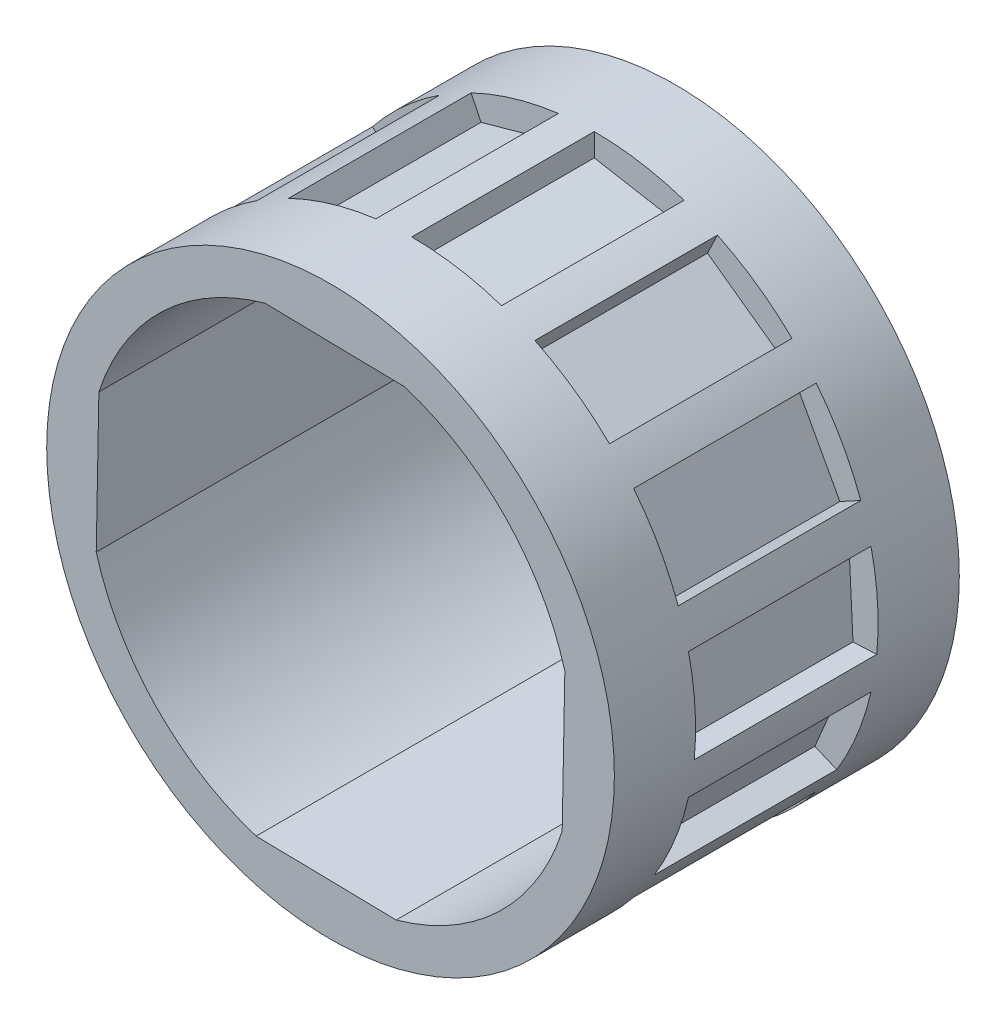
from build123d import *

# Parameters (mm, degrees)
BOSS_EXTRUDE1_DEPTH = 6.35
SKETCH3_R           = 9.875
BOSS_EXTRUDE3_DEPTH = 2.825
SKETCH7_R           = 9.875
BOSS_EXTRUDE5_DEPTH = 2.825


with BuildPart() as part:
    # Sketch1 → Boss-Extrude1 (new body)
    with BuildSketch(Plane.XY):
        with BuildLine():
            Line((0, 9.081), (2.981324224, 8.551667078))
            Line((2.981324224, 8.551667078), (3.126108811, 9.367127025))
            ThreePointArc((3.126108811, 9.367127025), (3.712801822, 9.150449586), (4.284601924, 8.897067571))
            Line((4.284601924, 8.897067571), (3.940098235, 8.181698289))
            Line((3.940098235, 8.181698289), (6.396509598, 6.411237704))
            Line((6.396509598, 6.411237704), (6.880770815, 7.083122051))
            ThreePointArc((6.880770815, 7.083122051), (7.315350136, 6.633345867), (7.720585889, 6.156961793))
            Line((7.720585889, 6.156961793), (7.099811692, 5.661910891))
            Line((7.099811692, 5.661910891), (8.544787799, 3.000984074))
            Line((8.544787799, 3.000984074), (9.272611772, 3.396217886))
            ThreePointArc((9.272611772, 3.396217886), (9.469003638, 2.802426646), (9.627413133, 2.197394223))
            Line((9.627413133, 2.197394223), (8.853320371, 2.020712601))
            Line((8.853320371, 2.020712601), (9.00066598, -1.003651256))
            Line((9.00066598, -1.003651256), (9.827898246, -0.963348883))
            ThreePointArc((9.827898246, -0.963348883), (9.74720484, -1.583547541), (9.627413133, -2.197394223))
            Line((9.627413133, -2.197394223), (8.853320371, -2.020712601))
            Line((8.853320371, -2.020712601), (7.673851879, -4.809501146))
            Line((7.673851879, -4.809501146), (8.436648941, -5.132112591))
            ThreePointArc((8.436648941, -5.132112591), (8.094852581, -5.655880717), (7.720585889, -6.156961793))
            Line((7.720585889, -6.156961793), (7.099811692, -5.661910891))
            Line((7.099811692, -5.661910891), (4.827137299, -7.66277035))
            Line((4.827137299, -7.66277035), (5.374417845, -8.284398459))
            ThreePointArc((5.374417845, -8.284398459), (4.839215493, -8.607997352), (4.284601924, -8.897067571))
            Line((4.284601924, -8.897067571), (3.940098235, -8.181698289))
            Line((3.940098235, -8.181698289), (1.024348976, -8.998333907))
            Line((1.024348976, -8.998333907), (1.247717382, -9.795857611))
            ThreePointArc((1.247717382, -9.795857611), (0.625112426, -9.855194542), (0, -9.875))
            Line((0, -9.875), (0, -9.081))
            Line((0, -9.081), (-2.981324224, -8.551667078))
            Line((-2.981324224, -8.551667078), (-3.126108811, -9.367127025))
            ThreePointArc((-3.126108811, -9.367127025), (-3.712801822, -9.150449586), (-4.284601924, -8.897067571))
            Line((-4.284601924, -8.897067571), (-3.940098235, -8.181698289))
            Line((-3.940098235, -8.181698289), (-6.396509598, -6.411237704))
            Line((-6.396509598, -6.411237704), (-6.880770815, -7.083122051))
            ThreePointArc((-6.880770815, -7.083122051), (-7.315350136, -6.633345867), (-7.720585889, -6.156961793))
            Line((-7.720585889, -6.156961793), (-7.099811692, -5.661910891))
            Line((-7.099811692, -5.661910891), (-8.544787799, -3.000984074))
            Line((-8.544787799, -3.000984074), (-9.272611772, -3.396217886))
            ThreePointArc((-9.272611772, -3.396217886), (-9.469003638, -2.802426646), (-9.627413133, -2.197394223))
            Line((-9.627413133, -2.197394223), (-8.853320371, -2.020712601))
            Line((-8.853320371, -2.020712601), (-9.00066598, 1.003651256))
            Line((-9.00066598, 1.003651256), (-9.827898246, 0.963348883))
            ThreePointArc((-9.827898246, 0.963348883), (-9.74720484, 1.583547541), (-9.627413133, 2.197394223))
            Line((-9.627413133, 2.197394223), (-8.853320371, 2.020712601))
            Line((-8.853320371, 2.020712601), (-7.673851879, 4.809501146))
            Line((-7.673851879, 4.809501146), (-8.436648941, 5.132112591))
            ThreePointArc((-8.436648941, 5.132112591), (-8.094852581, 5.655880717), (-7.720585889, 6.156961793))
            Line((-7.720585889, 6.156961793), (-7.099811692, 5.661910891))
            Line((-7.099811692, 5.661910891), (-4.827137299, 7.66277035))
            Line((-4.827137299, 7.66277035), (-5.374417845, 8.284398459))
            ThreePointArc((-5.374417845, 8.284398459), (-4.839215493, 8.607997352), (-4.284601924, 8.897067571))
            Line((-4.284601924, 8.897067571), (-3.940098235, 8.181698289))
            Line((-3.940098235, 8.181698289), (-1.024348976, 8.998333907))
            Line((-1.024348976, 8.998333907), (-1.247717382, 9.795857611))
            ThreePointArc((-1.247717382, 9.795857611), (-0.625112426, 9.855194542), (0, 9.875))
            Line((0, 9.875), (0, 9.081))
        make_face()
        with BuildLine():
            Line((2.58926817, 8.059275113), (-2.283002739, 8.151326487))
            ThreePointArc((-2.283002739, 8.151326487), (-5.871524586, 6.097657258), (-8.059275113, 2.58926817))
            Line((-8.059275113, 2.58926817), (-8.151326487, -2.283002739))
            ThreePointArc((-8.151326487, -2.283002739), (-6.097657258, -5.871524586), (-2.58926817, -8.059275113))
            Line((-2.58926817, -8.059275113), (2.283002739, -8.151326487))
            ThreePointArc((2.283002739, -8.151326487), (5.871524586, -6.097657258), (8.059275113, -2.58926817))
            Line((8.059275113, -2.58926817), (8.151326487, 2.283002739))
            ThreePointArc((8.151326487, 2.283002739), (6.097657258, 5.871524586), (2.58926817, 8.059275113))
        make_face(mode=Mode.SUBTRACT)
    extrude(amount=BOSS_EXTRUDE1_DEPTH)

    # Sketch3 → Boss-Extrude3 (add)
    with BuildSketch(Plane.XY.offset(6.35)):
        Circle(SKETCH3_R)
        with BuildLine():
            Line((-2.283002739, 8.151326487), (2.58926817, 8.059275113))
            ThreePointArc((2.58926817, 8.059275113), (6.097657258, 5.871524586), (8.151326487, 2.283002739))
            Line((8.151326487, 2.283002739), (8.059275113, -2.58926817))
            ThreePointArc((8.059275113, -2.58926817), (5.871524586, -6.097657258), (2.283002739, -8.151326487))
            Line((2.283002739, -8.151326487), (-2.58926817, -8.059275113))
            ThreePointArc((-2.58926817, -8.059275113), (-6.097657258, -5.871524586), (-8.151326487, -2.283002739))
            Line((-8.151326487, -2.283002739), (-8.059275113, 2.58926817))
            ThreePointArc((-8.059275113, 2.58926817), (-5.871524586, 6.097657258), (-2.283002739, 8.151326487))
        make_face(mode=Mode.SUBTRACT)
    extrude(amount=BOSS_EXTRUDE3_DEPTH)

    # Sketch7 → Boss-Extrude5 (add)
    with BuildSketch(Plane(origin=(0, 0, 0), x_dir=(-1, 0, 0), z_dir=(0, 0, -1))):
        Circle(SKETCH7_R)
        with BuildLine():
            Line((-2.58926817, 8.059275113), (2.283002739, 8.151326487))
            ThreePointArc((2.283002739, 8.151326487), (5.871524586, 6.097657258), (8.059275113, 2.58926817))
            Line((8.059275113, 2.58926817), (8.151326487, -2.283002739))
            ThreePointArc((8.151326487, -2.283002739), (6.097657258, -5.871524586), (2.58926817, -8.059275113))
            Line((2.58926817, -8.059275113), (-2.283002739, -8.151326487))
            ThreePointArc((-2.283002739, -8.151326487), (-5.871524586, -6.097657258), (-8.059275113, -2.58926817))
            Line((-8.059275113, -2.58926817), (-8.151326487, 2.283002739))
            ThreePointArc((-8.151326487, 2.283002739), (-6.097657258, 5.871524586), (-2.58926817, 8.059275113))
        make_face(mode=Mode.SUBTRACT)
    extrude(amount=BOSS_EXTRUDE5_DEPTH)


solid = part.part
